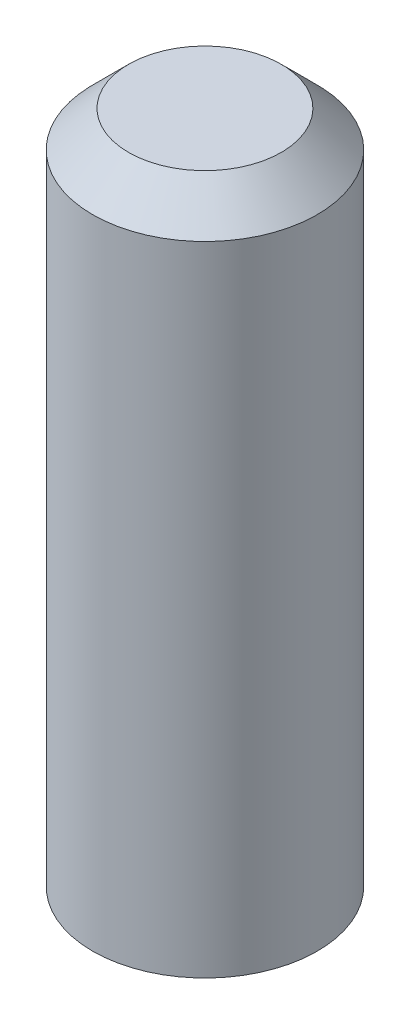
from build123d import *

# Parameters (mm, degrees)
SKETCH1_R           = 2.5
BOSS_EXTRUDE1_DEPTH = 15
CHAMFER1_SIZE       = 0.8


with BuildPart() as part:
    # Sketch1 → Boss-Extrude1 (new body)
    with BuildSketch(Plane(origin=(0, 0, 0), x_dir=(1, 0, 0), z_dir=(0, 1, 0))):
        Circle(SKETCH1_R)
    extrude(amount=BOSS_EXTRUDE1_DEPTH)

    # Chamfer1
    chamfer1_edges = [part.edges().sort_by_distance(p)[0] for p in [
        (-2.5, 15, 0),
    ]]
    chamfer(chamfer1_edges, length=CHAMFER1_SIZE)


solid = part.part
